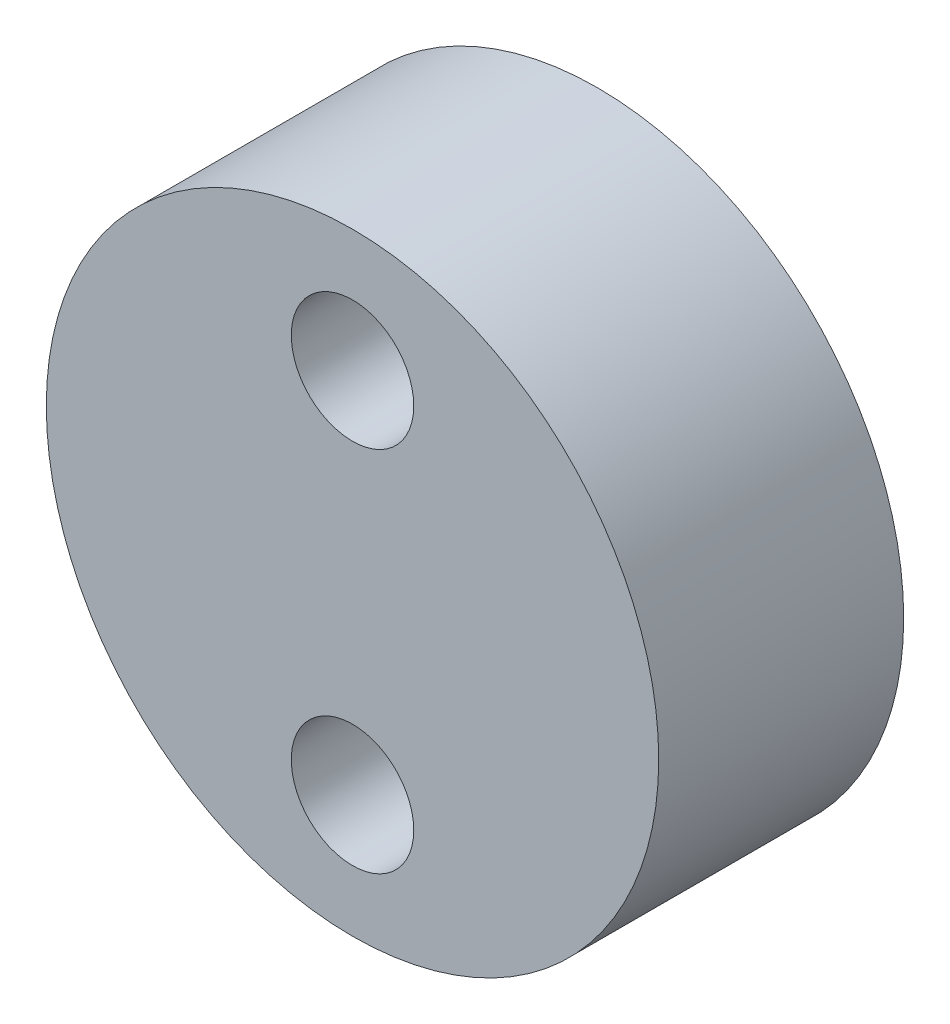
from build123d import *

# Parameters (mm, degrees)
SKETCH2_R           = 25
SKETCH2_R_2         = 5
BOSS_EXTRUDE1_DEPTH = 20


with BuildPart() as part:
    # Sketch2 → Boss-Extrude1 (new body)
    with BuildSketch(Plane.XY):
        Circle(SKETCH2_R)
        with Locations((0, 15)):
            Circle(SKETCH2_R_2, mode=Mode.SUBTRACT)
        with Locations((0, -15)):
            Circle(SKETCH2_R_2, mode=Mode.SUBTRACT)
    extrude(amount=BOSS_EXTRUDE1_DEPTH)


solid = part.part
